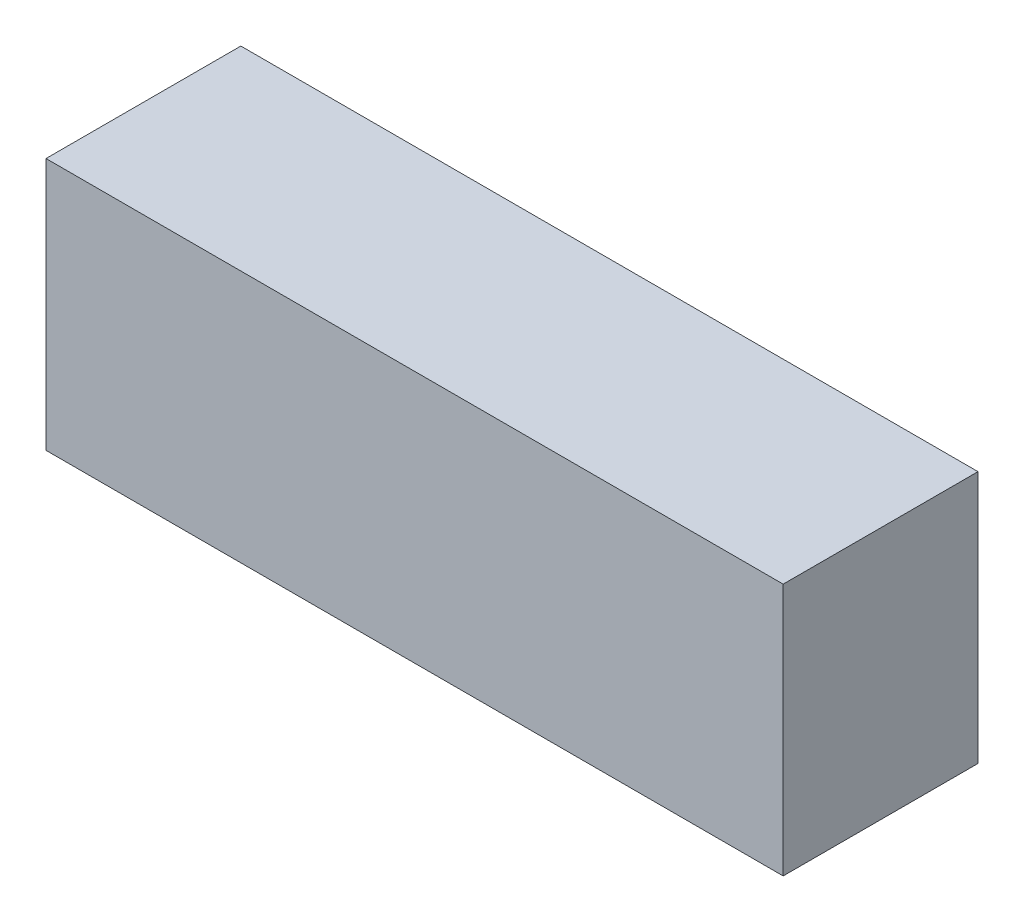
from build123d import *

# Parameters (mm, degrees)
SKETCH_1_W      = 70
SKETCH_1_H      = 24
EXTRUDE_1_DEPTH = 18.5


with BuildPart() as part:
    # 草图1 → 凸台-拉伸1 (new body)
    with BuildSketch(Plane.XY):
        with Locations((-2.913226903, 12)):
            Rectangle(SKETCH_1_W, SKETCH_1_H)
    extrude(amount=EXTRUDE_1_DEPTH)


solid = part.part
